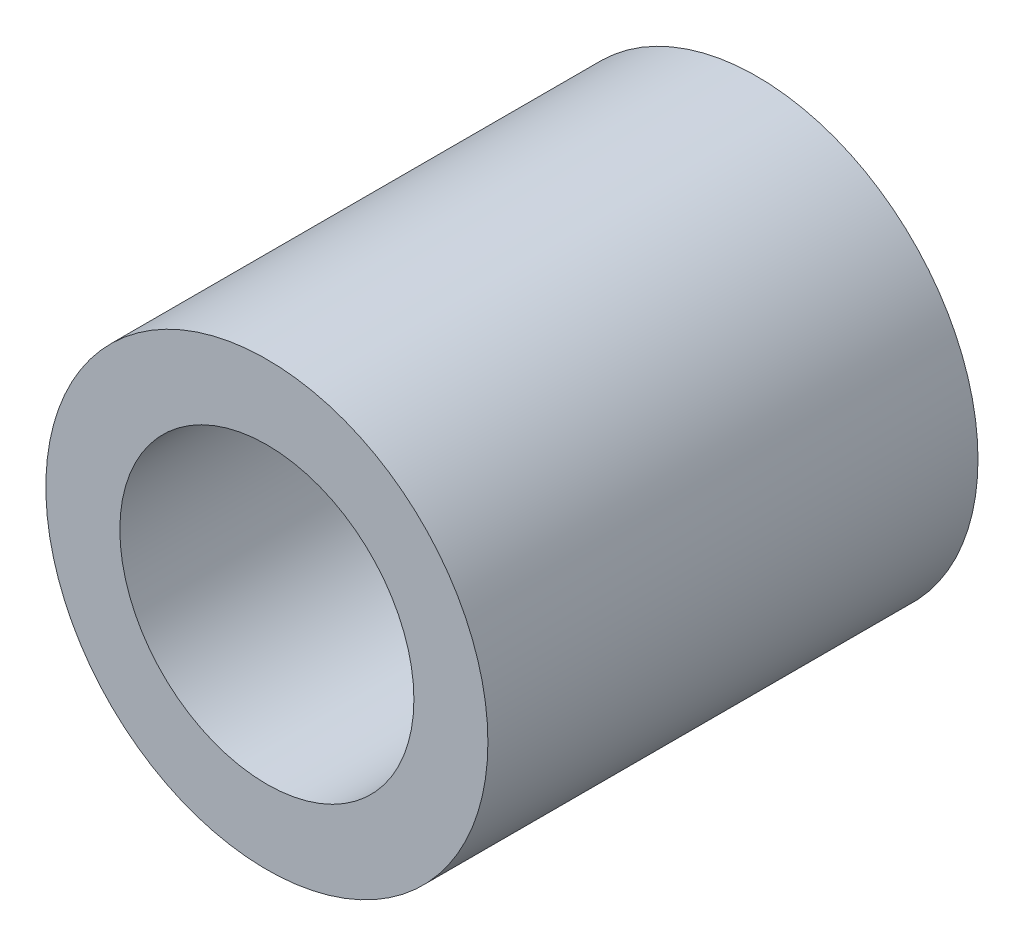
from build123d import *

# Parameters (mm, degrees)
SKETCH1_R      = 4.51
SKETCH1_R_2    = 3
EXTRUDE1_DEPTH = 5


with BuildPart() as part:
    # Sketch1 → Extrude1 (new body, symmetric)
    with BuildSketch(Plane.XY):
        Circle(SKETCH1_R)
        Circle(SKETCH1_R_2, mode=Mode.SUBTRACT)
    extrude(amount=EXTRUDE1_DEPTH, both=True)


solid = part.part
